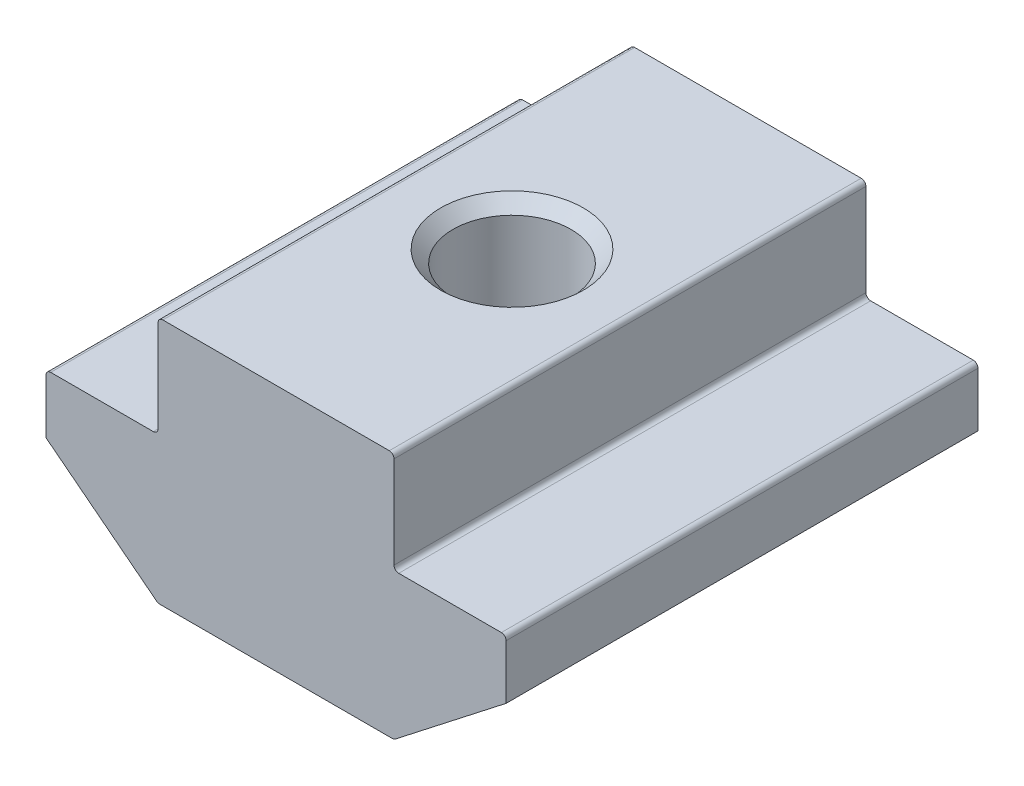
from build123d import *

# Parameters (mm, degrees)
EXTRUDE_1_DEPTH = 10
FILLET_1_R      = 0.2


with BuildPart() as part:
    # Эскиз1 → Бобышка-Вытянуть1 (new body, symmetric)
    with BuildSketch(Plane.XY):
        Polygon((5, 0), (-5, 0), (-5, -4.3), (-9.75, -4.3), (-9.75, -6.8), (-5, -10.5), (5, -10.5), (9.75, -6.8), (9.75, -4.3), (5, -4.3), align=None)
    extrude(amount=EXTRUDE_1_DEPTH, both=True)

    # Эскиз4 → Отверстие обработанное метчиком M64 (revolve, cut)
    with BuildSketch(Plane(origin=(0, 0, 0), x_dir=(0, 0, 1), z_dir=(1, 0, 0))):
        Polygon((0, 0), (0, 10.5), (3.025, 10.5), (2.5, 9.975), (2.5, 0.525), (3.025, 0), align=None)
    revolve(axis=Axis((0, 6.35, 0), (0, -1, 0)), mode=Mode.SUBTRACT)

    # Скругление1
    fillet_1_edges = [part.edges().sort_by_distance(p)[0] for p in [
        (-5, 0, 0),
        (5, 0, 0),
        (5, -4.3, 0),
        (9.75, -4.3, 0),
        (5, -10.5, 0),
        (-5, -10.5, 0),
        (-9.75, -4.3, 0),
        (-5, -4.3, 0),
    ]]
    fillet(fillet_1_edges, radius=FILLET_1_R)


solid = part.part
